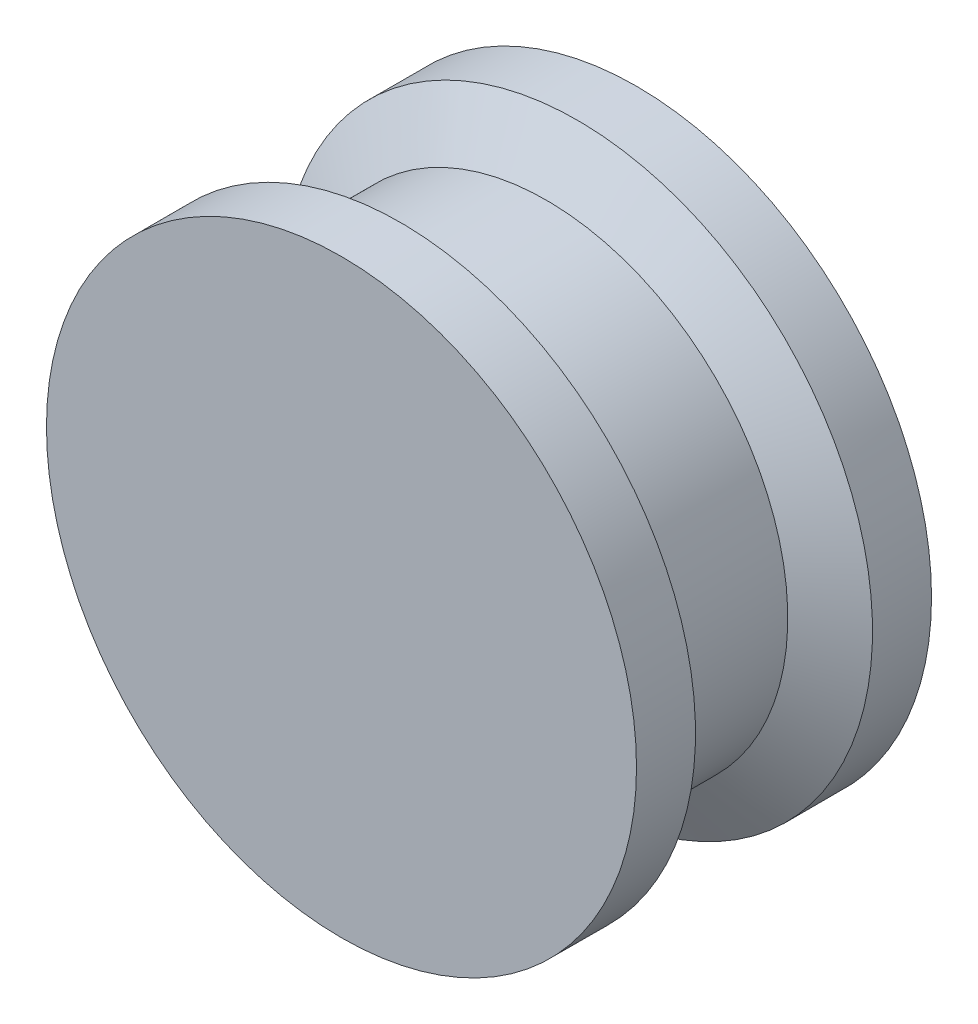
from build123d import *

# Parameters (mm, degrees)
SKETCH1_R           = 10
BOSS_EXTRUDE1_DEPTH = 5


with BuildPart() as part:
    # Sketch1 → Boss-Extrude1 (new body, symmetric)
    with BuildSketch(Plane.XY):
        Circle(SKETCH1_R)
    extrude(amount=BOSS_EXTRUDE1_DEPTH, both=True)

    # Sketch2 → Cut-Revolve1 (revolve, cut)
    with BuildSketch(Plane(origin=(0, 0, 0), x_dir=(1, 0, 0), z_dir=(0, 1, 0))):
        Polygon((10, 3), (8.178550696, 1.948385754), (8.178550696, -1.948385754), (10, -3), align=None)
    revolve(axis=Axis((0, 0, -6.38791657), (0, 0, 1)), mode=Mode.SUBTRACT)


solid = part.part
